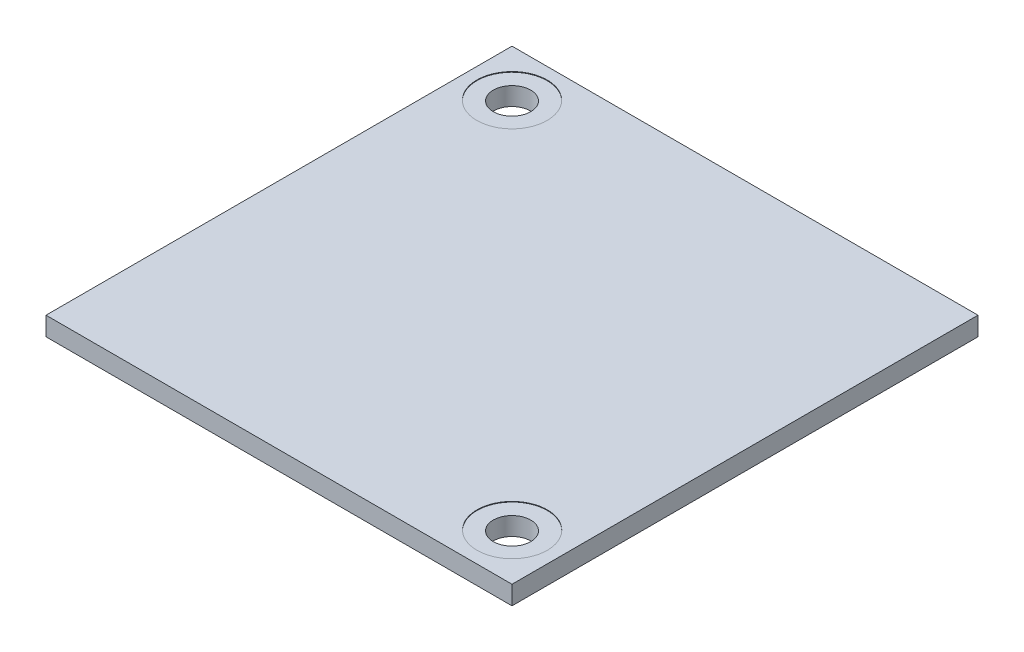
from build123d import *

# Parameters (mm, degrees)
SKETCH1_W           = 39.8
SKETCH1_H           = 39.8
BOSS_EXTRUDE1_DEPTH = 1.6
SKETCH10_R          = 3
CUT_EXTRUDE6_DEPTH  = 0.05
SKETCH11_R          = 1.6
CUT_EXTRUDE7_DEPTH  = 1.6


with BuildPart() as part:
    # Sketch1 → Boss-Extrude1 (new body)
    with BuildSketch(Plane(origin=(0, 0, 0), x_dir=(1, 0, 0), z_dir=(0, 1, 0))):
        with Locations((-0.3, 0.3)):
            Rectangle(SKETCH1_W, SKETCH1_H)
    extrude(amount=BOSS_EXTRUDE1_DEPTH)

    # Sketch10 → Cut-Extrude6 (cut)
    with BuildSketch(Plane(origin=(0, 1.6, 0), x_dir=(1, 0, 0), z_dir=(0, 1, 0))):
        with Locations((-16.2, 16.2)):
            Circle(SKETCH10_R)
        with Locations((15.599994551, -15.586708083)):
            Circle(SKETCH10_R)
    extrude(amount=-CUT_EXTRUDE6_DEPTH, mode=Mode.SUBTRACT)

    # Sketch11 → Cut-Extrude7 (cut)
    with BuildSketch(Plane(origin=(0, 1.6, 0), x_dir=(1, 0, 0), z_dir=(0, 1, 0))):
        with Locations((-16.2, 16.2)):
            Circle(SKETCH11_R)
        with Locations((15.6, -15.6)):
            Circle(SKETCH11_R)
    extrude(amount=-CUT_EXTRUDE7_DEPTH, mode=Mode.SUBTRACT)


solid = part.part
